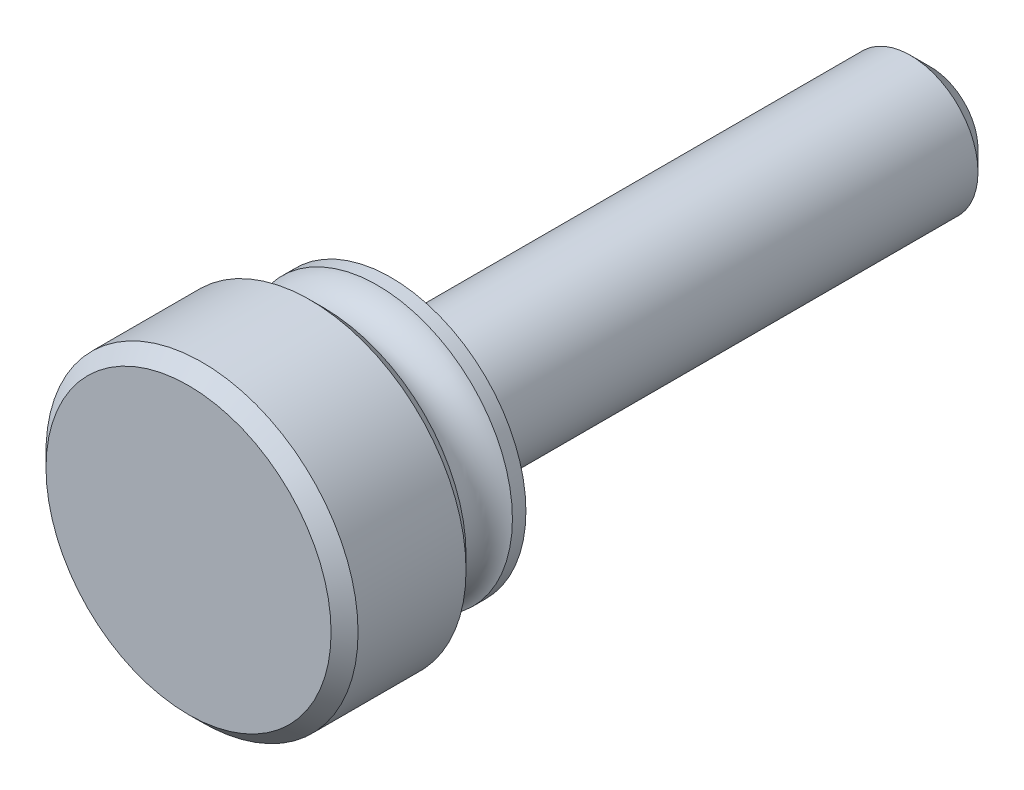
from build123d import *

# Parameters (mm, degrees)
SKETCH1_R           = 3.175
EXTRUDE1_DEPTH      = 25.4
CHAMFER2_SIZE       = 0.9525
SKETCH27_R          = 6.35
BOSS_EXTRUDE4_DEPTH = 3.175
SKETCH21_R          = 7.3421875
BOSS_EXTRUDE1_DEPTH = 6.35
CHAMFER3_SIZE       = 0.635


with BuildPart() as part:
    # Sketch1 → Extrude1 (new body)
    with BuildSketch(Plane.XY):
        Circle(SKETCH1_R)
    extrude(amount=-EXTRUDE1_DEPTH)

    # Chamfer2
    chamfer2_edges = [part.edges().sort_by_distance(p)[0] for p in [
        (-3.175, 0, -25.4),
    ]]
    chamfer(chamfer2_edges, length=CHAMFER2_SIZE)

    # Sketch27 → Boss-Extrude4 (add)
    with BuildSketch(Plane.XY):
        Circle(SKETCH27_R)
    extrude(amount=BOSS_EXTRUDE4_DEPTH)

    # Sketch21 → Boss-Extrude1 (add)
    with BuildSketch(Plane.XY.offset(3.175)):
        Circle(SKETCH21_R)
    extrude(amount=BOSS_EXTRUDE1_DEPTH)

    # Sketch28 → Cut-Revolve1 (revolve, cut)
    with BuildSketch(Plane(origin=(0, 0, 0), x_dir=(0, 0, -1), z_dir=(1, 0, 0))):
        with BuildLine():
            Line((-3.175, 6.35), (-0.635, 6.35))
            ThreePointArc((-0.635, 6.35), (-1.905, 5.469889405), (-3.175, 6.35))
        make_face()
    revolve(axis=Axis((0, 0, 0), (0, 0, -1)), mode=Mode.SUBTRACT)

    # Chamfer3
    chamfer3_edges = [part.edges().sort_by_distance(p)[0] for p in [
        (-7.3421875, 0, 3.175),
        (-7.3421875, 0, 9.525),
    ]]
    chamfer(chamfer3_edges, length=CHAMFER3_SIZE)


solid = part.part
